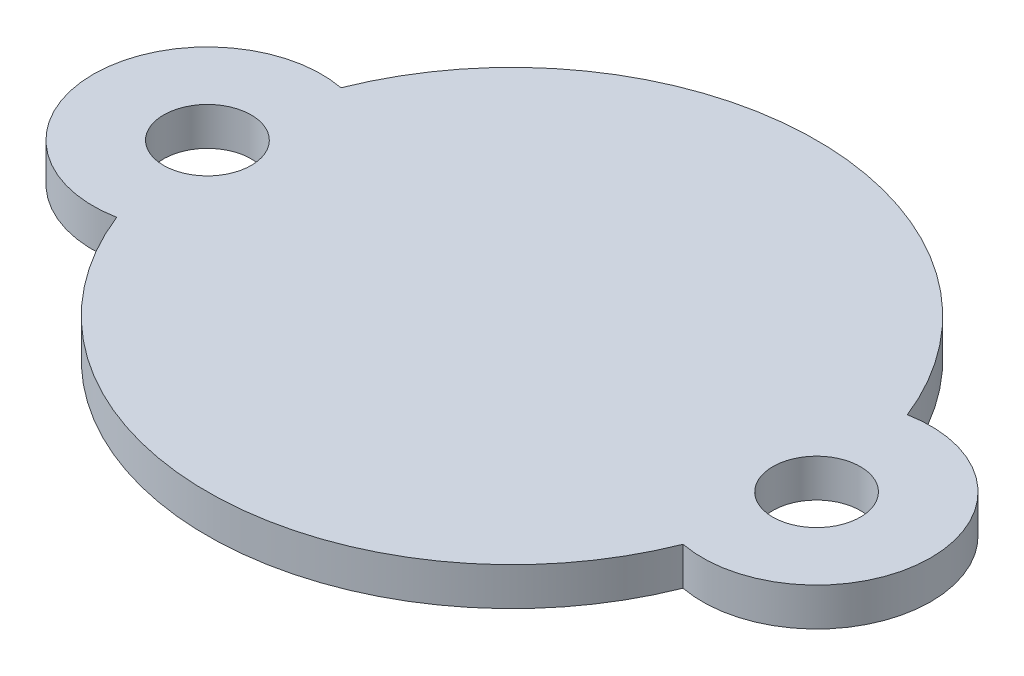
from build123d import *

# Parameters (mm, degrees)
SKETCH1_R           = 1.15
BOSS_EXTRUDE1_DEPTH = 1


with BuildPart() as part:
    # Sketch1 → Boss-Extrude1 (new body)
    with BuildSketch(Plane(origin=(0, 0, 0), x_dir=(1, 0, 0), z_dir=(0, 1, 0))):
        with BuildLine():
            ThreePointArc((7.4375, -2.946793809), (11, 0), (7.4375, 2.946793809))
            ThreePointArc((7.4375, 2.946793809), (0, 8), (-7.4375, 2.946793809))
            ThreePointArc((-7.4375, 2.946793809), (-11, 0), (-7.4375, -2.946793809))
            ThreePointArc((-7.4375, -2.946793809), (0, -8), (7.4375, -2.946793809))
        make_face()
        with Locations((8, 0)):
            Circle(SKETCH1_R, mode=Mode.SUBTRACT)
        with Locations((-8, 0)):
            Circle(SKETCH1_R, mode=Mode.SUBTRACT)
    extrude(amount=BOSS_EXTRUDE1_DEPTH)


solid = part.part
